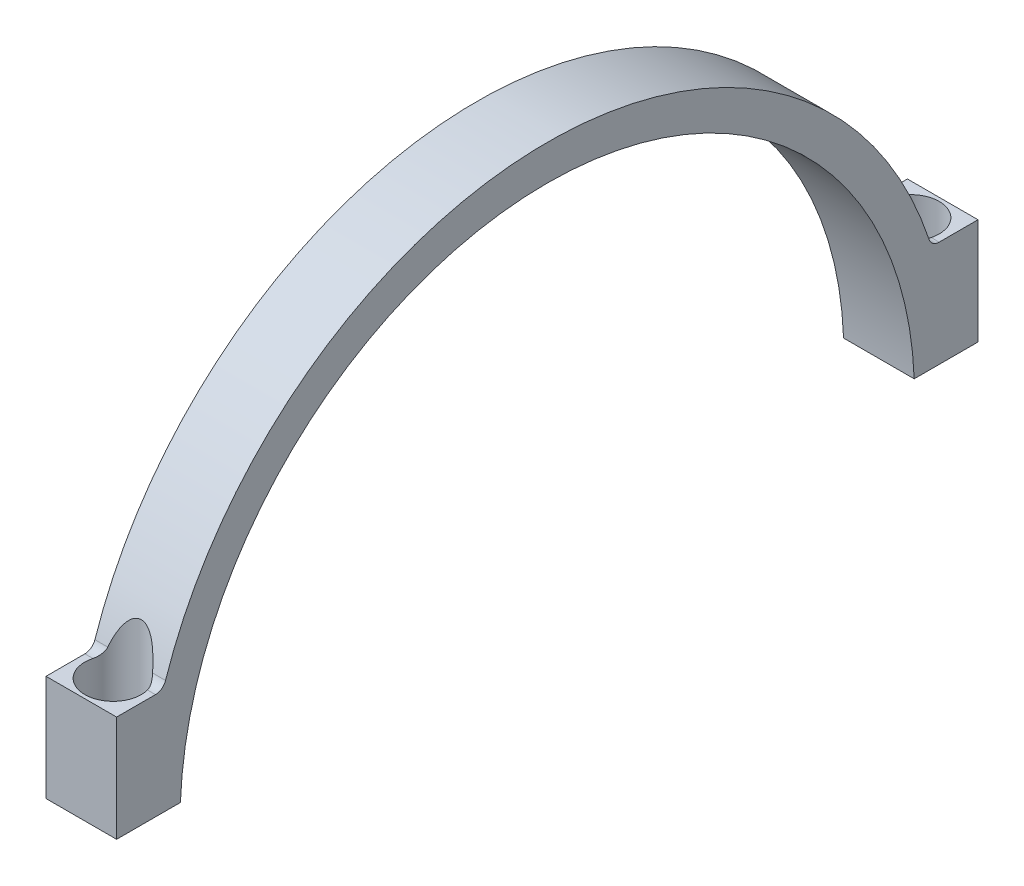
from build123d import *

# Parameters (mm, degrees)
BOSS_EXTRUDE1_DEPTH        = 10
M4_TAPPED_HOLE1_AT_2_COUNT = 2
M4_TAPPED_HOLE1_AT_2_PITCH = 113
SKETCH7_R                  = 4
CUT_EXTRUDE1_DEPTH         = 10
CUT_EXTRUDE1_DEPTH_BACK    = 6.6


with BuildPart() as part:
    # Sketch1 → Boss-Extrude1 (new body)
    with BuildSketch(Plane(origin=(0, 0, 0), x_dir=(0, 0, -1), z_dir=(1, 0, 0))):
        with BuildLine():
            Line((-61.001524227, 2), (-51.961524227, 2))
            ThreePointArc((-51.961524227, 2), (0, 52), (51.961524227, 2))
            Line((51.961524227, 2), (60.998475773, 2))
            Line((60.998475773, 2), (60.998475773, 17))
            Line((60.998475773, 17), (55.497747702, 17))
            ThreePointArc((55.497747702, 17), (54.620689683, 17.283131383), (54.07472853, 18.025641026))
            ThreePointArc((54.07472853, 18.025641026), (0, 57), (-54.07472853, 18.025641026))
            ThreePointArc((-54.07472853, 18.025641026), (-54.620689683, 17.283131383), (-55.497747702, 17))
            Line((-55.497747702, 17), (-61.001524227, 17))
            Line((-61.001524227, 17), (-61.001524227, 2))
        make_face()
    extrude(amount=BOSS_EXTRUDE1_DEPTH)

    # Sketch4 → M4 Tapped Hole1 (revolve, cut)
    with BuildSketch(Plane(origin=(5, 17, -56.498475773), x_dir=(0, 0, 1), z_dir=(1, 0, 0))):
        Polygon((0, 0), (0, 21.091420021), (1.65, 20.1), (1.65, 0), align=None)
    m4_tapped_hole1 = revolve(axis=Axis((5, 23.35, -56.498475773), (0, -1, 0)), mode=Mode.SUBTRACT)

    # M4 Tapped Hole1 at 2: M4 Tapped Hole1 ×2
    with Locations(*[(0, 0, i * M4_TAPPED_HOLE1_AT_2_PITCH) for i in range(1, M4_TAPPED_HOLE1_AT_2_COUNT)]):
        add(m4_tapped_hole1, mode=Mode.SUBTRACT)

    # Sketch7 → Cut-Extrude1 (cut, two sides)
    with BuildSketch(Plane(origin=(0, 17, 0), x_dir=(1, 0, 0), z_dir=(0, 1, 0))) as cut_extrude1_sk:
        with Locations((5, 56.498475773)):
            Circle(SKETCH7_R)
        with Locations((5, -56.501524227)):
            Circle(SKETCH7_R)
    extrude(amount=CUT_EXTRUDE1_DEPTH, mode=Mode.SUBTRACT)
    extrude(cut_extrude1_sk.sketch, amount=-CUT_EXTRUDE1_DEPTH_BACK, mode=Mode.SUBTRACT)


solid = part.part
